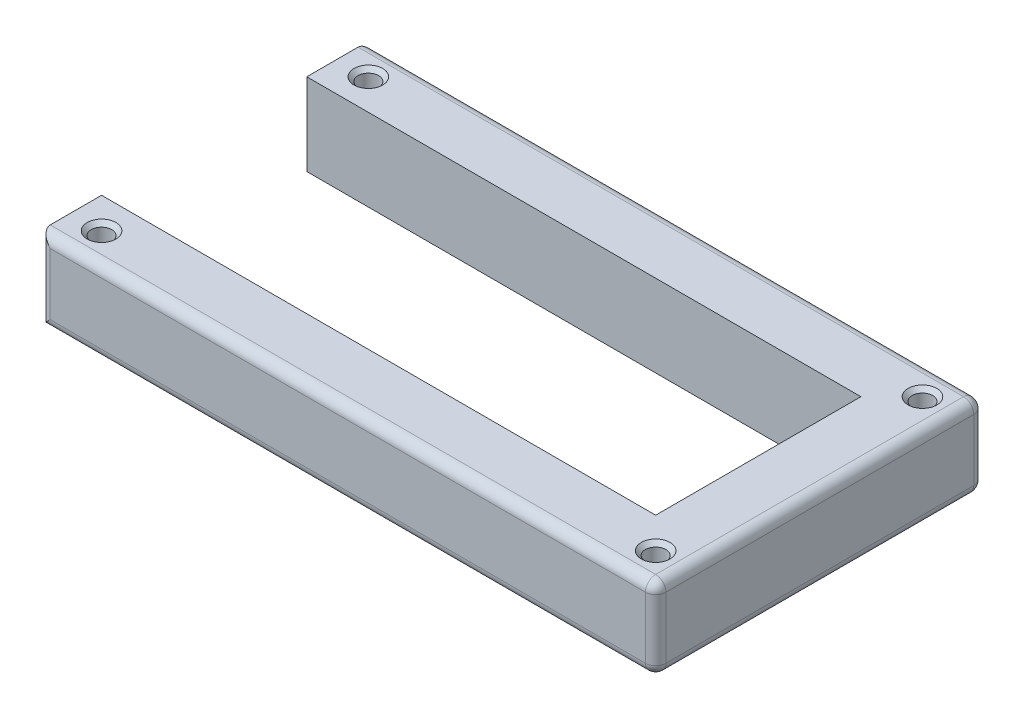
from build123d import *

# Parameters (mm, degrees)
BOSS_EXTRUDE1_DEPTH = 20
FILLET1_R           = 2.5
SKETCH2_R           = 2.5
CUT_EXTRUDE1_DEPTH  = 21
CHAMFER1_SIZE       = 1


with BuildPart() as part:
    # Sketch1 → Boss-Extrude1 (new body)
    with BuildSketch(Plane(origin=(0, 0, 0), x_dir=(1, 0, 0), z_dir=(0, 1, 0))):
        Polygon((0, 25), (-135, 25), (-135, 40), (15, 40), (15, -40), (-135, -40), (-135, -25), (0, -25), align=None)
    extrude(amount=BOSS_EXTRUDE1_DEPTH)

    # Fillet1
    fillet1_edges = [part.edges().sort_by_distance(p)[0] for p in [
        (-135, 10, -40),
        (15, 10, -40),
        (15, 10, 40),
        (-135, 10, 40),
        (-60, 20, 40),
        (15, 20, 0),
        (-60, 20, -40),
        (-60, 0, -40),
        (15, 0, 0),
        (-60, 0, 40),
    ]]
    fillet(fillet1_edges, radius=FILLET1_R)

    # Sketch2 → Cut-Extrude1 (cut, through all)
    with BuildSketch(Plane(origin=(0, 20, 0), x_dir=(1, 0, 0), z_dir=(0, 1, 0))):
        with Locations((7.5, 32.5)):
            Circle(SKETCH2_R)
        with Locations((7.5, -32.5)):
            Circle(SKETCH2_R)
        with Locations((-127.5, 32.5)):
            Circle(SKETCH2_R)
        with Locations((-127.5, -32.5)):
            Circle(SKETCH2_R)
    extrude(amount=-CUT_EXTRUDE1_DEPTH, mode=Mode.SUBTRACT)

    # Chamfer1
    chamfer1_edges = [part.edges().sort_by_distance(p)[0] for p in [
        (5, 20, 32.5),
        (-130, 20, -32.5),
        (-130, 20, 32.5),
        (5, 20, -32.5),
    ]]
    chamfer(chamfer1_edges, length=CHAMFER1_SIZE)


solid = part.part
